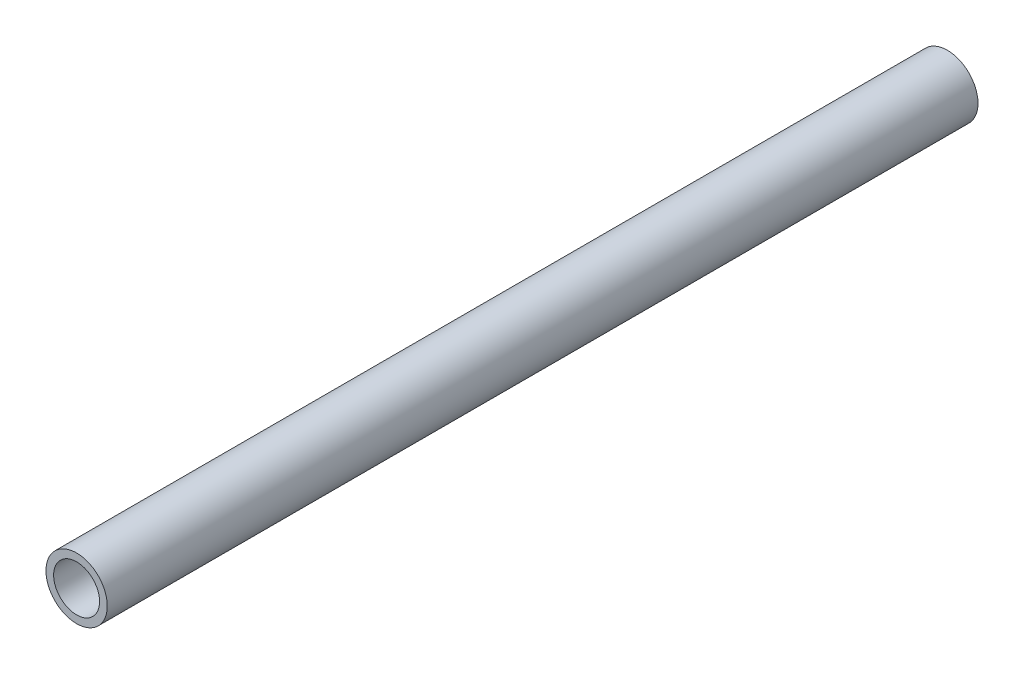
from build123d import *

# Parameters (mm, degrees)
SKETCH1_R           = 6.35
SKETCH1_R_2         = 4.7625
BOSS_EXTRUDE1_DEPTH = 180.366666667


with BuildPart() as part:
    # Sketch1 → Boss-Extrude1 (new body)
    with BuildSketch(Plane.XY):
        Circle(SKETCH1_R)
        Circle(SKETCH1_R_2, mode=Mode.SUBTRACT)
    extrude(amount=BOSS_EXTRUDE1_DEPTH)


solid = part.part
